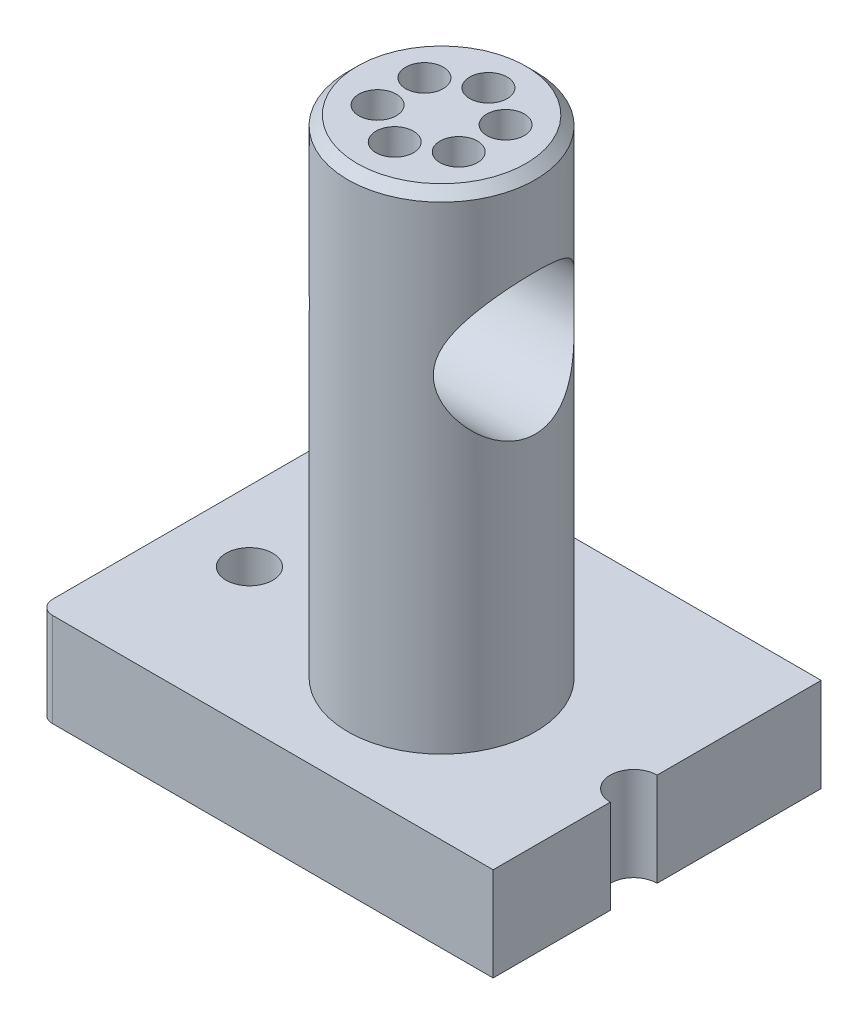
from build123d import *

# Parameters (mm, degrees)
SKETCH1_R                = 20
BOSS_EXTRUDE1_DEPTH      = 20
SKETCH2_R                = 5
CUT_EXTRUDE1_DEPTH       = 21
SKETCH3_R                = 9
CUT_EXTRUDE2_DEPTH       = 10
SKETCH4_R                = 20
BOSS_EXTRUDE2_DEPTH      = 104
BOSS_EXTRUDE2_DEPTH_BACK = 20
SKETCH5_R                = 15
CUT_EXTRUDE3_DEPTH       = 49.5
CUT_EXTRUDE3_DEPTH_BACK  = 49.5
CHAMFER1_SIZE            = 2
CUT_EXTRUDE4_REACH       = 126
SKETCH6_R                = 4


with BuildPart() as part:
    # Sketch1 → Boss-Extrude1 (new body)
    with BuildSketch(Plane(origin=(0, 0, 0), x_dir=(1, 0, 0), z_dir=(0, 1, 0))):
        with BuildLine():
            Line((-45.5, 35), (48.5, 35))
            Line((48.5, 35), (48.5, 0))
            ThreePointArc((48.5, 0), (43.5, -5), (48.5, -10))
            Line((48.5, -10), (48.5, -35))
            Line((48.5, -35), (-45.5, -35))
            ThreePointArc((-45.5, -35), (-47.621320344, -34.121320344), (-48.5, -32))
            Line((-48.5, -32), (-48.5, 32))
            ThreePointArc((-48.5, 32), (-47.621320344, 34.121320344), (-45.5, 35))
        make_face()
        with Locations((7.5, -5)):
            Circle(SKETCH1_R, mode=Mode.SUBTRACT)
    extrude(amount=BOSS_EXTRUDE1_DEPTH)

    # Sketch2 → Cut-Extrude1 (cut, through all)
    with BuildSketch(Plane.XZ):
        with Locations((-33.5, 5)):
            Circle(SKETCH2_R)
    extrude(amount=-CUT_EXTRUDE1_DEPTH, mode=Mode.SUBTRACT)

    # Sketch3 → Cut-Extrude2 (cut)
    with BuildSketch(Plane.XZ):
        with Locations((-33.5, 5)):
            Circle(SKETCH3_R)
    extrude(amount=-CUT_EXTRUDE2_DEPTH, mode=Mode.SUBTRACT)


with BuildPart() as body_2:
    # Sketch4 → Boss-Extrude2 (new body, two sides)
    with BuildSketch(Plane(origin=(0, 20, 0), x_dir=(1, 0, 0), z_dir=(0, 1, 0))) as boss_extrude2_sk:
        with Locations((7.5, -5)):
            Circle(SKETCH4_R)
    extrude(amount=BOSS_EXTRUDE2_DEPTH)
    extrude(boss_extrude2_sk.sketch, amount=-BOSS_EXTRUDE2_DEPTH_BACK)

    # Sketch5 → Cut-Extrude3 (cut, two sides)
    with BuildSketch(Plane(origin=(0, 0, 0), x_dir=(0, 0, -1), z_dir=(1, 0, 0))) as cut_extrude3_sk:
        with Locations((-5, 90)):
            Circle(SKETCH5_R)
    extrude(amount=CUT_EXTRUDE3_DEPTH, mode=Mode.SUBTRACT)
    extrude(cut_extrude3_sk.sketch, amount=-CUT_EXTRUDE3_DEPTH_BACK, mode=Mode.SUBTRACT)

    # Chamfer1
    chamfer1_edges = [body_2.edges().sort_by_distance(p)[0] for p in [
        (-12.5, 124, 5),
    ]]
    chamfer(chamfer1_edges, length=CHAMFER1_SIZE)

    # Sketch6 → Cut-Extrude4 (cut, up to next)
    with BuildSketch(Plane(origin=(0, 124, 0), x_dir=(1, 0, 0), z_dir=(0, 1, 0)), mode=Mode.PRIVATE) as cut_extrude4_sk1:
        with Locations((7.5, 5)):
            Circle(SKETCH6_R)
    cut_extrude4_tool1 = extrude(cut_extrude4_sk1.sketch, amount=-CUT_EXTRUDE4_REACH, mode=Mode.PRIVATE) & body_2.part
    add(cut_extrude4_tool1.solids().sort_by_distance((7.5, 124, -5))[0], mode=Mode.SUBTRACT)
    # Sketch6 → Cut-Extrude4 (cut, up to next)
    with BuildSketch(Plane(origin=(0, 124, 0), x_dir=(1, 0, 0), z_dir=(0, 1, 0)), mode=Mode.PRIVATE) as cut_extrude4_sk2:
        with Locations((16.160254038, 0)):
            Circle(SKETCH6_R)
    cut_extrude4_tool2 = extrude(cut_extrude4_sk2.sketch, amount=-CUT_EXTRUDE4_REACH, mode=Mode.PRIVATE) & body_2.part
    add(cut_extrude4_tool2.solids().sort_by_distance((16.160254, 124, 0))[0], mode=Mode.SUBTRACT)
    # Sketch6 → Cut-Extrude4 (cut, up to next)
    with BuildSketch(Plane(origin=(0, 124, 0), x_dir=(1, 0, 0), z_dir=(0, 1, 0)), mode=Mode.PRIVATE) as cut_extrude4_sk3:
        with Locations((16.160254038, -10)):
            Circle(SKETCH6_R)
    cut_extrude4_tool3 = extrude(cut_extrude4_sk3.sketch, amount=-CUT_EXTRUDE4_REACH, mode=Mode.PRIVATE) & body_2.part
    add(cut_extrude4_tool3.solids().sort_by_distance((16.160254, 124, 10))[0], mode=Mode.SUBTRACT)
    # Sketch6 → Cut-Extrude4 (cut, up to next)
    with BuildSketch(Plane(origin=(0, 124, 0), x_dir=(1, 0, 0), z_dir=(0, 1, 0)), mode=Mode.PRIVATE) as cut_extrude4_sk4:
        with Locations((7.5, -15)):
            Circle(SKETCH6_R)
    cut_extrude4_tool4 = extrude(cut_extrude4_sk4.sketch, amount=-CUT_EXTRUDE4_REACH, mode=Mode.PRIVATE) & body_2.part
    add(cut_extrude4_tool4.solids().sort_by_distance((7.5, 124, 15))[0], mode=Mode.SUBTRACT)
    # Sketch6 → Cut-Extrude4 (cut, up to next)
    with BuildSketch(Plane(origin=(0, 124, 0), x_dir=(1, 0, 0), z_dir=(0, 1, 0)), mode=Mode.PRIVATE) as cut_extrude4_sk5:
        with Locations((-1.160254038, -10)):
            Circle(SKETCH6_R)
    cut_extrude4_tool5 = extrude(cut_extrude4_sk5.sketch, amount=-CUT_EXTRUDE4_REACH, mode=Mode.PRIVATE) & body_2.part
    add(cut_extrude4_tool5.solids().sort_by_distance((-1.160254, 124, 10))[0], mode=Mode.SUBTRACT)
    # Sketch6 → Cut-Extrude4 (cut, up to next)
    with BuildSketch(Plane(origin=(0, 124, 0), x_dir=(1, 0, 0), z_dir=(0, 1, 0)), mode=Mode.PRIVATE) as cut_extrude4_sk6:
        with Locations((-1.160254038, 0)):
            Circle(SKETCH6_R)
    cut_extrude4_tool6 = extrude(cut_extrude4_sk6.sketch, amount=-CUT_EXTRUDE4_REACH, mode=Mode.PRIVATE) & body_2.part
    add(cut_extrude4_tool6.solids().sort_by_distance((-1.160254, 124, 0))[0], mode=Mode.SUBTRACT)


solid = Compound([part.part, body_2.part])
